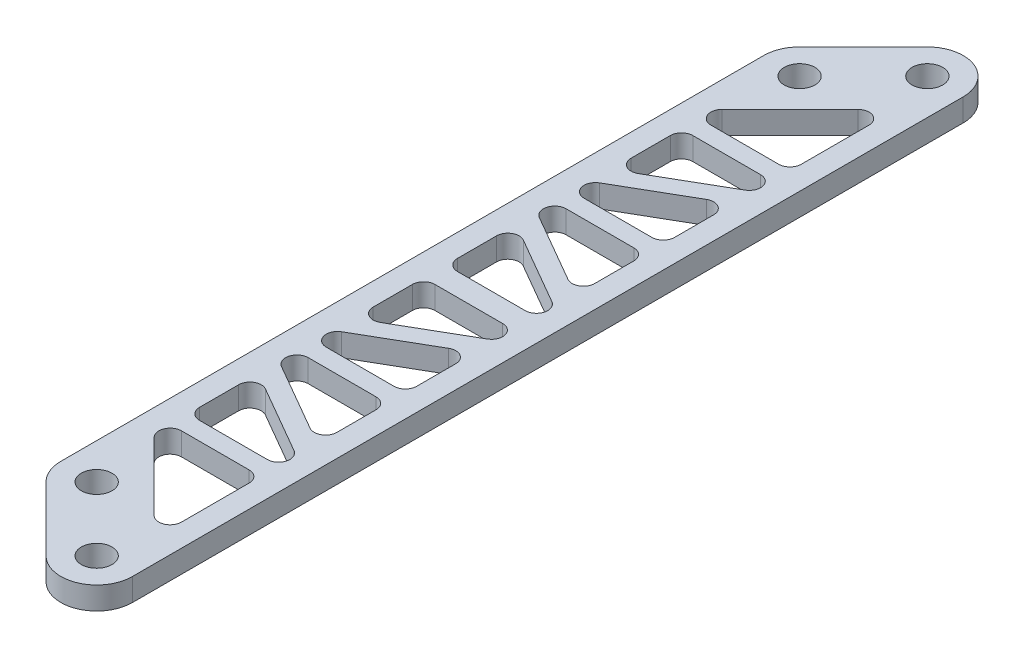
from build123d import *

# Parameters (mm, degrees)
SKETCH1_R                    = 2.0828
BOSS_EXTRUDE1_DEPTH          = 3.175
F_18_0_1695_DIAMETER_HOLE1_D = 4.3053
CUT_EXTRUDE2_DEPTH           = 3.175
MIRROR1_COPY_1_DEPTH         = 3.175


with BuildPart() as part:
    # Sketch1 → Boss-Extrude1 (new body)
    with BuildSketch(Plane(origin=(0, 0, 0), x_dir=(1, 0, 0), z_dir=(0, 1, 0))):
        with BuildLine():
            Line((0, 0), (0, 49.391408666))
            ThreePointArc((0, 49.391408666), (0.383256806, 51.318170741), (1.474679849, 52.951600757))
            Line((1.474679849, 52.951600757), (10.45493597, 61.931856878))
            ThreePointArc((10.45493597, 61.931856878), (15.941890136, 63.023279921), (19.05, 58.371664787))
            Line((19.05, 58.371664787), (19.05, 0))
            Line((19.05, 0), (0, 0))
        make_face()
        with Locations(Location((14.015128061, 58.371664787, 0), (0, 0, 270))):
            Circle(SKETCH1_R, mode=Mode.SUBTRACT)
        with Locations(Location((5.034871939, 49.391408666, 0), (0, 0, 270))):
            Circle(SKETCH1_R, mode=Mode.SUBTRACT)
        with BuildLine():
            Line((13.164967985, 49.439274202), (3.639967985, 39.914274202))
            ThreePointArc((3.639967985, 39.914274202), (3.295841242, 38.184232238), (4.7625, 37.204242187))
            Line((4.7625, 37.204242187), (14.2875, 37.204242187))
            ThreePointArc((14.2875, 37.204242187), (15.410032015, 37.669210172), (15.875, 38.791742187))
            Line((15.875, 38.791742187), (15.875, 48.316742187))
            ThreePointArc((15.875, 48.316742187), (14.895009949, 49.783400945), (13.164967985, 49.439274202))
        make_face(mode=Mode.SUBTRACT)
    boss_extrude1 = extrude(amount=BOSS_EXTRUDE1_DEPTH)

    # #18 (0.1695) Diameter Hole1 (through all)
    with Locations(Plane(origin=(0, 0, 0), x_dir=(-1, 0, 0), z_dir=(0, -1, 0))):
        with Locations((-14.015128061, 58.371664787), (-5.034871939, 49.391408666)):
            f_18_0_1695_diameter_hole1 = Hole(F_18_0_1695_DIAMETER_HOLE1_D / 2)

    # Sketch5 → Cut-Extrude2 (cut)
    with BuildSketch(Plane(origin=(0, 3.175, 0), x_dir=(1, 0, 0), z_dir=(0, 1, 0))):
        with BuildLine():
            Line((14.2875, 34.664242187), (4.7625, 34.664242187))
            ThreePointArc((4.7625, 34.664242187), (3.639967985, 34.199274202), (3.175, 33.076742187))
            Line((3.175, 33.076742187), (3.175, 27.577480873))
            ThreePointArc((3.175, 27.577480873), (3.96875, 26.202665545), (5.55625, 26.202665545))
            Line((5.55625, 26.202665545), (15.08125, 31.701926859))
            ThreePointArc((15.08125, 31.701926859), (15.820907249, 33.487617421), (14.2875, 34.664242187))
        make_face()
        with BuildLine():
            Line((13.49375, 27.852443939), (3.96875, 22.353182625))
            ThreePointArc((3.96875, 22.353182625), (3.229092751, 20.567492062), (4.7625, 19.390867296))
            Line((4.7625, 19.390867296), (14.2875, 19.390867296))
            ThreePointArc((14.2875, 19.390867296), (15.410032015, 19.855835281), (15.875, 20.978367296))
            Line((15.875, 20.978367296), (15.875, 26.47762861))
            ThreePointArc((15.875, 26.47762861), (15.08125, 27.852443939), (13.49375, 27.852443939))
        make_face()
    cut_extrude2 = extrude(amount=-CUT_EXTRUDE2_DEPTH, mode=Mode.SUBTRACT)

    # Mirror2: Cut-Extrude2 across plane
    add(cut_extrude2.mirror(Plane(origin=(0, 0, -18.120867296), x_dir=(1, 0, 0), z_dir=(0, 0, -1))), mode=Mode.SUBTRACT)

    # Mirror1: Boss-Extrude1, #18 (0.1695) Diameter Hole1, Cut-Extrude2 across plane
    add(boss_extrude1.mirror(Plane(origin=(19.05, 3.175, 0), x_dir=(1, 0, 0), z_dir=(0, 0, -1))))
    add(f_18_0_1695_diameter_hole1.mirror(Plane(origin=(19.05, 3.175, 0), x_dir=(1, 0, 0), z_dir=(0, 0, -1))), mode=Mode.SUBTRACT)
    add(cut_extrude2.mirror(Plane(origin=(19.05, 3.175, 0), x_dir=(1, 0, 0), z_dir=(0, 0, -1))), mode=Mode.SUBTRACT)

    # Mirror1 copy 1 sketch → Mirror1 copy 1 (cut)
    with BuildSketch(Plane(origin=(0, 3.175, 36.241734593), x_dir=(1, 0, 0), z_dir=(0, 1, 0))):
        with BuildLine():
            Line((14.2875, 34.664242187), (4.7625, 34.664242187))
            ThreePointArc((4.7625, 34.664242187), (3.639967985, 34.199274202), (3.175, 33.076742187))
            Line((3.175, 33.076742187), (3.175, 27.577480873))
            ThreePointArc((3.175, 27.577480873), (3.96875, 26.202665545), (5.55625, 26.202665545))
            Line((5.55625, 26.202665545), (15.08125, 31.701926859))
            ThreePointArc((15.08125, 31.701926859), (15.820907249, 33.487617421), (14.2875, 34.664242187))
        make_face()
        with BuildLine():
            Line((13.49375, 27.852443939), (3.96875, 22.353182625))
            ThreePointArc((3.96875, 22.353182625), (3.229092751, 20.567492062), (4.7625, 19.390867296))
            Line((4.7625, 19.390867296), (14.2875, 19.390867296))
            ThreePointArc((14.2875, 19.390867296), (15.410032015, 19.855835281), (15.875, 20.978367296))
            Line((15.875, 20.978367296), (15.875, 26.47762861))
            ThreePointArc((15.875, 26.47762861), (15.08125, 27.852443939), (13.49375, 27.852443939))
        make_face()
    extrude(amount=-MIRROR1_COPY_1_DEPTH, mode=Mode.SUBTRACT)


solid = part.part
